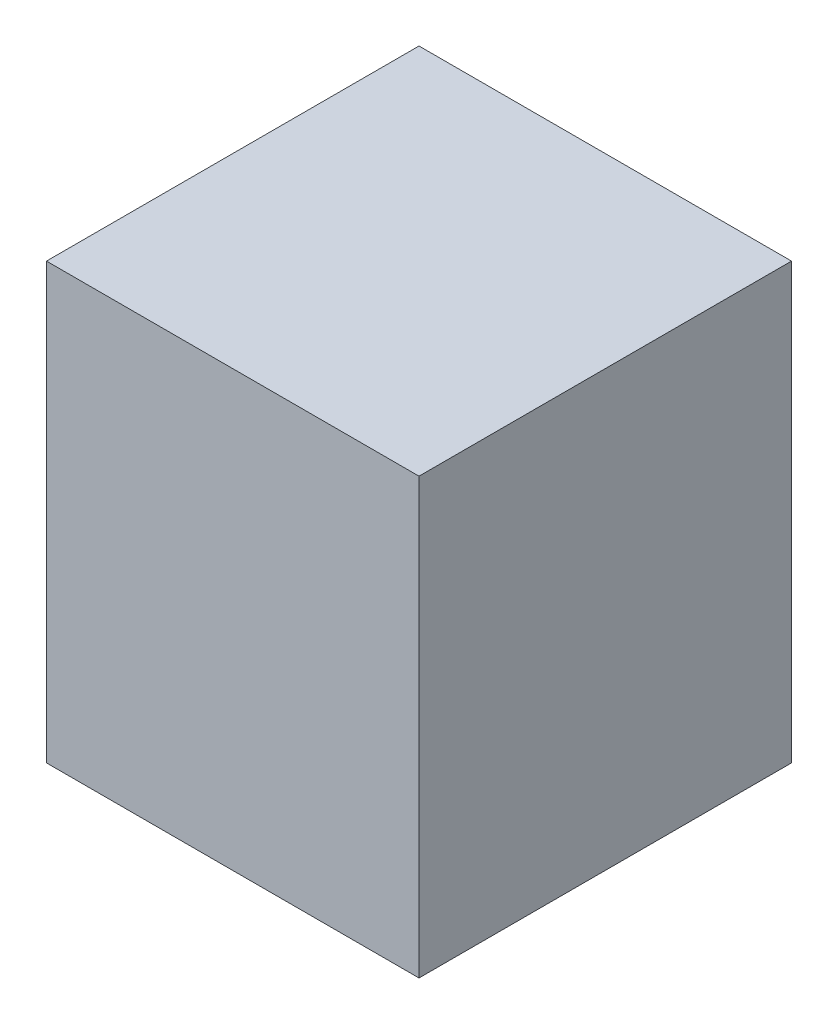
from build123d import *

# Parameters (mm, degrees)
SKETCH1_W           = 76.2
SKETCH1_H           = 88.9
BOSS_EXTRUDE1_DEPTH = 38.1


with BuildPart() as part:
    # Sketch1 → Boss-Extrude1 (new body, symmetric)
    with BuildSketch(Plane.XY):
        Rectangle(SKETCH1_W, SKETCH1_H)
    extrude(amount=BOSS_EXTRUDE1_DEPTH, both=True)


solid = part.part
